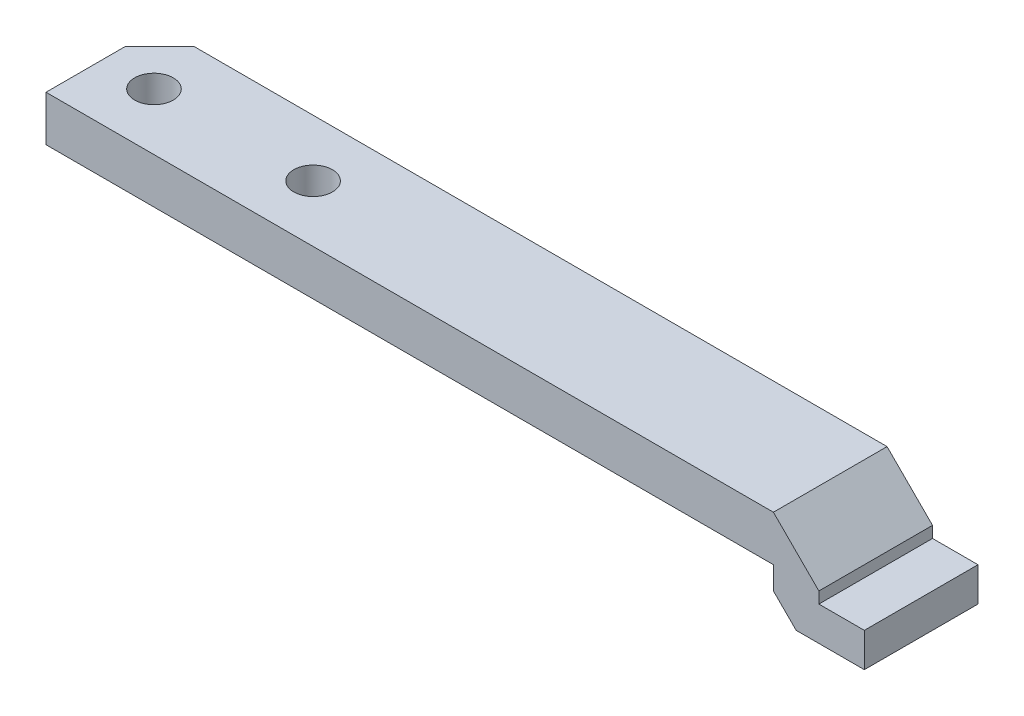
from build123d import *

# Parameters (mm, degrees)
BOSS_EXTRUDE1_DEPTH = 10
CHAMFER1_SIZE       = 3
CHAMFER4_SIZE       = 4
CHAMFER5_SIZE       = 2
CUT_EXTRUDE1_REACH  = 10
SKETCH4_R           = 1.7


with BuildPart() as part:
    # Sketch2 → Boss-Extrude1 (new body)
    with BuildSketch(Plane.XY):
        Polygon((-41.668551289, 7.497735583), (-41.668551289, 3.497735583), (22.331448711, 3.497735583), (22.331448711, -0.502264417), (30.331448711, -0.502264417), (30.331448711, 2.497735583), (26.331448711, 2.497735583), (26.331448711, 7.497735583), align=None)
    extrude(amount=BOSS_EXTRUDE1_DEPTH)

    # Chamfer1
    chamfer1_edges = [part.edges().sort_by_distance(p)[0] for p in [
        (-41.668551289, 5.497735583, 0),
    ]]
    chamfer(chamfer1_edges, length=CHAMFER1_SIZE)

    # Chamfer4
    chamfer4_edges = [part.edges().sort_by_distance(p)[0] for p in [
        (26.331448711, 7.497735583, 5),
    ]]
    chamfer(chamfer4_edges, length=CHAMFER4_SIZE)

    # Chamfer5
    chamfer5_edges = [part.edges().sort_by_distance(p)[0] for p in [
        (22.331448711, -0.502264417, 5),
    ]]
    chamfer(chamfer5_edges, length=CHAMFER5_SIZE)

    # Sketch4 → Cut-Extrude1 (cut, up to next)
    with BuildSketch(Plane(origin=(0, 7.497735583, 0), x_dir=(1, 0, 0), z_dir=(0, 1, 0)), mode=Mode.PRIVATE) as cut_extrude1_sk1:
        with Locations((-37.168551289, -5)):
            Circle(SKETCH4_R)
    cut_extrude1_tool1 = extrude(cut_extrude1_sk1.sketch, amount=-CUT_EXTRUDE1_REACH, mode=Mode.PRIVATE) & part.part
    add(cut_extrude1_tool1.solids().sort_by_distance((-37.168551, 7.497736, 5))[0], mode=Mode.SUBTRACT)
    # Sketch4 → Cut-Extrude1 (cut, up to next)
    with BuildSketch(Plane(origin=(0, 7.497735583, 0), x_dir=(1, 0, 0), z_dir=(0, 1, 0)), mode=Mode.PRIVATE) as cut_extrude1_sk2:
        with Locations((-23.168551289, -5)):
            Circle(SKETCH4_R)
    cut_extrude1_tool2 = extrude(cut_extrude1_sk2.sketch, amount=-CUT_EXTRUDE1_REACH, mode=Mode.PRIVATE) & part.part
    add(cut_extrude1_tool2.solids().sort_by_distance((-23.168551, 7.497736, 5))[0], mode=Mode.SUBTRACT)


solid = part.part
